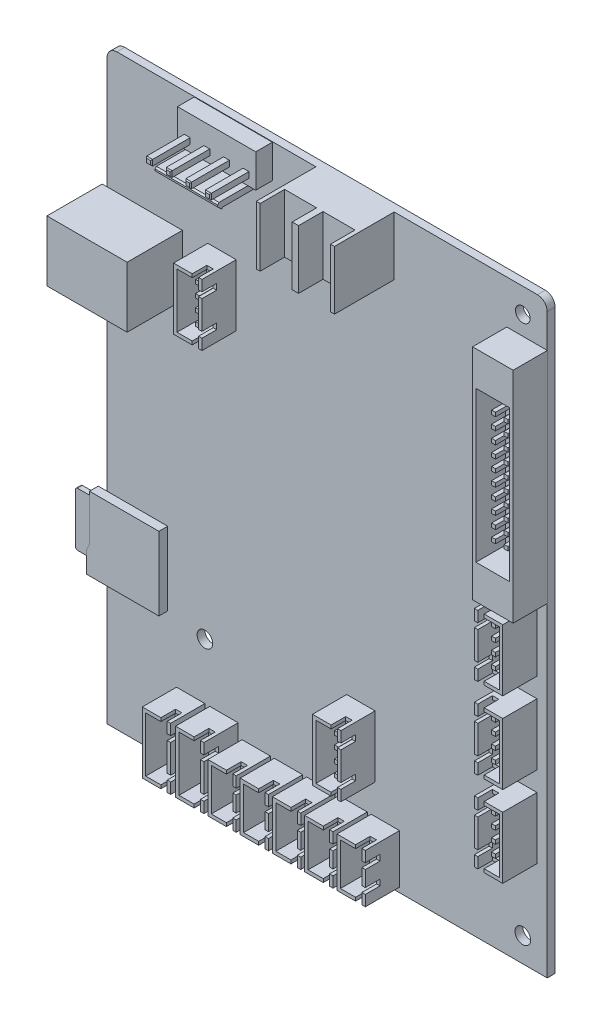
from build123d import *

# Parameters (mm, degrees)
SKETCH_1_R             = 1.5
EXTRUDE_1_DEPTH        = 1.6
SKETCH_2_W             = 16.4
SKETCH_2_H             = 12.4
EXTRUDE_2_DEPTH        = 11.3
SKETCH_3_W             = 3
SKETCH_3_H             = 5.4
CUT_EXTRUDE_1_DEPTH    = 9
EXTRUDE_3_DEPTH        = 1.8
SKETCH_5_W             = 1
SKETCH_5_H             = 11
EXTRUDE_4_DEPTH        = 3
FILLET_1_R             = 0.5
SKETCH_6_W             = 5.8
SKETCH_6_H             = 12.6
EXTRUDE_5_DEPTH        = 7
SKETCH_7_W             = 4.4
SKETCH_7_H             = 11.2
CUT_EXTRUDE_2_DEPTH    = 6
SKETCH_8_W             = 1.3
SKETCH_8_H             = 0.7
SKETCH_8_W_2           = 0.7
SKETCH_8_H_2           = 1.2
CUT_EXTRUDE_3_DEPTH    = 3
PATTERN_LINEAR_1_COUNT = 2
PATTERN_LINEAR_1_PITCH = 6.8
SKETCH_11_W            = 5.8
SKETCH_11_H            = 12.6
EXTRUDE_7_DEPTH        = 7
SKETCH_13_W            = 4.4
SKETCH_13_H            = 11.2
CUT_EXTRUDE_4_DEPTH    = 6
SKETCH_15_W            = 1.3
SKETCH_15_H            = 0.7
SKETCH_15_W_2          = 0.7
SKETCH_15_H_2          = 1.2
CUT_EXTRUDE_5_DEPTH    = 3
SKETCH_17_W            = 0.8
SKETCH_17_H            = 0.8
EXTRUDE_8_DEPTH        = 4.5
EXTRUDE_8_DEPTH_BACK   = 4
SKETCH_19_W            = 5.8
SKETCH_19_H            = 12.6
EXTRUDE_9_DEPTH        = 7
SKETCH_21_W            = 4.4
SKETCH_21_H            = 11.2
CUT_EXTRUDE_6_DEPTH    = 6
SKETCH_23_W            = 1.3
SKETCH_23_H            = 0.7
SKETCH_23_W_2          = 0.7
SKETCH_23_H_2          = 1.2
CUT_EXTRUDE_7_DEPTH    = 3
SKETCH_25_W            = 0.8
SKETCH_25_H            = 0.8
EXTRUDE_10_DEPTH       = 4.5
EXTRUDE_10_DEPTH_BACK  = 4
SKETCH_27_W            = 5.8
SKETCH_27_H            = 12.6
EXTRUDE_11_DEPTH       = 7
SKETCH_29_W            = 4.4
SKETCH_29_H            = 11.2
CUT_EXTRUDE_8_DEPTH    = 6
SKETCH_31_W            = 1.3
SKETCH_31_H            = 0.7
SKETCH_31_W_2          = 0.7
SKETCH_31_H_2          = 1.2
CUT_EXTRUDE_9_DEPTH    = 3
EXTRUDE_START          = -4
SKETCH_33_W            = 0.8
SKETCH_33_H            = 0.8
EXTRUDE_12_DEPTH       = 8.5
PATTERN_LINEAR_2_COUNT = 3
PATTERN_LINEAR_2_PITCH = 16.6
SKETCH_35_W            = 5.8
SKETCH_35_H            = 10
EXTRUDE_13_DEPTH       = 7
SKETCH_37_W            = 4.4
SKETCH_37_H            = 8.6
CUT_EXTRUDE_10_DEPTH   = 6
SKETCH_39_W            = 1.3
SKETCH_39_H            = 0.7
SKETCH_39_W_2          = 0.7
SKETCH_39_H_2          = 1.2
CUT_EXTRUDE_11_DEPTH   = 3
PATTERN_LINEAR_3_COUNT = 5
PATTERN_LINEAR_3_PITCH = 6.6
SKETCH_43_W            = 8.3
SKETCH_43_H            = 44.8
EXTRUDE_15_DEPTH       = 7
SKETCH_45_W            = 6.9
SKETCH_45_H            = 30.8
CUT_EXTRUDE_12_DEPTH   = 6
SKETCH_49_W            = 0.8
SKETCH_49_H            = 0.8
EXTRUDE_16_DEPTH       = 4.5
EXTRUDE_16_DEPTH_BACK  = 4
EXTRUDE_17_DEPTH       = 3.4
EXTRUDE_18_DEPTH       = 12.8
SKETCH_52_W            = 1.2
SKETCH_52_H            = 1.2
EXTRUDE_19_DEPTH       = 7.9
EXTRUDE_19_DEPTH_BACK  = 6
CHAMFER_1_SIZE         = 0.2
SKETCH_53_W            = 16
SKETCH_53_H            = 12
EXTRUDE_20_DEPTH       = 12.2
SKETCH_54_W            = 6.55
SKETCH_54_H            = 12
CUT_EXTRUDE_14_DEPTH   = 5
SKETCH_57_W            = 90
SKETCH_57_H            = 1.6
EXTRUDE_23_DEPTH       = 10
SKETCH_58_R            = 1.6
CUT_EXTRUDE_15_DEPTH   = 10
SKETCH_59_R            = 1.6
CUT_EXTRUDE_16_DEPTH   = 10
SKETCH_60_W            = 2
SKETCH_60_H            = 2
SKETCH_60_W_2          = 2.67575565
SKETCH_60_H_2          = 3.537085726
EXTRUDE_24_DEPTH       = 1.6


with BuildPart() as part:
    # Sketch 1 → Extrude 1 (new body)
    with BuildSketch(Plane.XY):
        with BuildLine():
            Line((43, -55), (-43, -55))
            ThreePointArc((-43, -55), (-44.414213562, -54.414213562), (-45, -53))
            Line((-45, -53), (-45, 53))
            ThreePointArc((-45, 53), (-44.414213562, 54.414213562), (-43, 55))
            Line((-43, 55), (43, 55))
            ThreePointArc((43, 55), (44.414213562, 54.414213562), (45, 53))
            Line((45, 53), (45, -53))
            ThreePointArc((45, -53), (44.414213562, -54.414213562), (43, -55))
        make_face()
        with Locations(Location((40, 50, 0), (0, 0, 180))):
            Circle(SKETCH_1_R, mode=Mode.SUBTRACT)
    extrude(amount=EXTRUDE_1_DEPTH)

    # Sketch 2 → Extrude 2 (add)
    with BuildSketch(Plane.XY.offset(1.6)):
        with Locations((-37.8, 23.9)):
            Rectangle(SKETCH_2_W, SKETCH_2_H)
    extrude(amount=EXTRUDE_2_DEPTH)

    # Sketch 3 → Cut-Extrude 1 (cut)
    with BuildSketch(Plane.ZY.offset(46)):
        Polygon((3, 28.7), (3, 19.1), (9.9, 19.1), (11.5, 20.7), (11.5, 27.1), (9.9, 28.7), align=None)
        with Locations((6.9, 23.9)):
            Rectangle(SKETCH_3_W, SKETCH_3_H, mode=Mode.SUBTRACT)
    extrude(amount=-CUT_EXTRUDE_1_DEPTH, mode=Mode.SUBTRACT)

    # Sketch 4 → Extrude 3 (add)
    with BuildSketch(Plane.XY.offset(1.6)):
        Polygon((-32.6, -23.8), (-32.6, -38.8), (-47.4, -38.8), (-47.4, -34.5), (-46.8, -33.188583942), (-46.8, -23.8), align=None)
    extrude(amount=EXTRUDE_3_DEPTH)

    # Sketch 5 → Extrude 4 (add)
    with BuildSketch(Plane.ZY.offset(46.8)):
        with Locations((2.8, -30.1)):
            Rectangle(SKETCH_5_W, SKETCH_5_H)
    extrude(amount=EXTRUDE_4_DEPTH)

    # Fillet 1
    fillet_1_edges = [part.edges().sort_by_distance(p)[0] for p in [
        (-49.8, -24.6, 2.8),
        (-49.8, -35.6, 2.8),
    ]]
    fillet(fillet_1_edges, radius=FILLET_1_R)

    # Sketch 6 → Extrude 5 (add)
    with BuildSketch(Plane.XY.offset(1.6)):
        with Locations((-27.9, -57.7)):
            Rectangle(SKETCH_6_W, SKETCH_6_H)
    extrude_5 = extrude(amount=EXTRUDE_5_DEPTH)

    # Sketch 7 → Cut-Extrude 2 (cut)
    with BuildSketch(Plane.XY.offset(8.6)):
        with Locations((-27.9, -57.7)):
            Rectangle(SKETCH_7_W, SKETCH_7_H)
    cut_extrude_2 = extrude(amount=-CUT_EXTRUDE_2_DEPTH, mode=Mode.SUBTRACT)

    # Sketch 8 → Cut-Extrude 3 (cut)
    with BuildSketch(Plane.XY.offset(8.6)):
        with Locations((-26.35, -51.75)):
            Rectangle(SKETCH_8_W, SKETCH_8_H)
        with Locations((-25.35, -61.2)):
            Rectangle(SKETCH_8_W_2, SKETCH_8_H_2)
        with Locations((-25.35, -54.2)):
            Rectangle(SKETCH_8_W_2, SKETCH_8_H_2)
        with Locations((-26.35, -63.65)):
            Rectangle(SKETCH_8_W, SKETCH_8_H)
    cut_extrude_3 = extrude(amount=-CUT_EXTRUDE_3_DEPTH, mode=Mode.SUBTRACT)

    # Pattern Linear 1: Extrude 5, Cut-Extrude 2, Cut-Extrude 3 ×2
    with Locations(*[(i * PATTERN_LINEAR_1_PITCH, 0, 0) for i in range(1, PATTERN_LINEAR_1_COUNT)]):
        add(extrude_5)
        add(cut_extrude_2, mode=Mode.SUBTRACT)
        add(cut_extrude_3, mode=Mode.SUBTRACT)

    # Sketch 11 → Extrude 7 (add)
    with BuildSketch(Plane(origin=(33.890716381, 27.460447967, 1.6), x_dir=(1, 0, 0), z_dir=(0, 0, 1))):
        with Locations((-26.990716381, -69.060447967)):
            Rectangle(SKETCH_11_W, SKETCH_11_H)
    extrude(amount=EXTRUDE_7_DEPTH)

    # Sketch 13 → Cut-Extrude 4 (cut)
    with BuildSketch(Plane(origin=(33.890716381, 27.460447967, 8.6), x_dir=(1, 0, 0), z_dir=(0, 0, 1))):
        with Locations((-26.990716381, -69.060447967)):
            Rectangle(SKETCH_13_W, SKETCH_13_H)
    extrude(amount=-CUT_EXTRUDE_4_DEPTH, mode=Mode.SUBTRACT)

    # Sketch 15 → Cut-Extrude 5 (cut)
    with BuildSketch(Plane(origin=(33.890716381, 27.460447967, 8.6), x_dir=(1, 0, 0), z_dir=(0, 0, 1))):
        with Locations((-25.440716381, -63.110447967)):
            Rectangle(SKETCH_15_W, SKETCH_15_H)
        with Locations((-24.440716381, -72.560447967)):
            Rectangle(SKETCH_15_W_2, SKETCH_15_H_2)
        with Locations((-24.440716381, -65.560447967)):
            Rectangle(SKETCH_15_W_2, SKETCH_15_H_2)
        with Locations((-25.440716381, -75.010447967)):
            Rectangle(SKETCH_15_W, SKETCH_15_H)
    extrude(amount=-CUT_EXTRUDE_5_DEPTH, mode=Mode.SUBTRACT)

    # Sketch 17 → Extrude 8 (add, two sides)
    with BuildSketch(Plane(origin=(33.890716381, 27.460447967, 2.6), x_dir=(1, 0, 0), z_dir=(0, 0, 1))) as extrude_8_sk:
        with Locations((-26.490716381, -67.810447967)):
            Rectangle(SKETCH_17_W, SKETCH_17_H)
        with Locations((-26.490716381, -65.310447967)):
            Rectangle(SKETCH_17_W, SKETCH_17_H)
        with Locations((-26.490716381, -70.310447967)):
            Rectangle(SKETCH_17_W, SKETCH_17_H)
        with Locations((-26.490716381, -72.810447967)):
            Rectangle(SKETCH_17_W, SKETCH_17_H)
    extrude(amount=EXTRUDE_8_DEPTH)
    extrude(extrude_8_sk.sketch, amount=-EXTRUDE_8_DEPTH_BACK)

    # Sketch 19 → Extrude 9 (add)
    with BuildSketch(Plane(origin=(2.842311538, 77.877367815, 1.6), x_dir=(1, 0, 0), z_dir=(0, 0, 1))):
        with Locations((-24.342311538, -53.777367815)):
            Rectangle(SKETCH_19_W, SKETCH_19_H)
    extrude(amount=EXTRUDE_9_DEPTH)

    # Sketch 21 → Cut-Extrude 6 (cut)
    with BuildSketch(Plane(origin=(2.842311538, 77.877367815, 8.6), x_dir=(1, 0, 0), z_dir=(0, 0, 1))):
        with Locations((-24.342311538, -53.777367815)):
            Rectangle(SKETCH_21_W, SKETCH_21_H)
    extrude(amount=-CUT_EXTRUDE_6_DEPTH, mode=Mode.SUBTRACT)

    # Sketch 23 → Cut-Extrude 7 (cut)
    with BuildSketch(Plane(origin=(2.842311538, 77.877367815, 8.6), x_dir=(1, 0, 0), z_dir=(0, 0, 1))):
        with Locations((-22.792311538, -47.827367815)):
            Rectangle(SKETCH_23_W, SKETCH_23_H)
        with Locations((-21.792311538, -57.277367815)):
            Rectangle(SKETCH_23_W_2, SKETCH_23_H_2)
        with Locations((-21.792311538, -50.277367815)):
            Rectangle(SKETCH_23_W_2, SKETCH_23_H_2)
        with Locations((-22.792311538, -59.727367815)):
            Rectangle(SKETCH_23_W, SKETCH_23_H)
    extrude(amount=-CUT_EXTRUDE_7_DEPTH, mode=Mode.SUBTRACT)

    # Sketch 25 → Extrude 10 (add, two sides)
    with BuildSketch(Plane(origin=(2.842311538, 77.877367815, 2.6), x_dir=(1, 0, 0), z_dir=(0, 0, 1))) as extrude_10_sk:
        with Locations((-23.842311538, -52.527367815)):
            Rectangle(SKETCH_25_W, SKETCH_25_H)
        with Locations((-23.842311538, -50.027367815)):
            Rectangle(SKETCH_25_W, SKETCH_25_H)
        with Locations((-23.842311538, -55.027367815)):
            Rectangle(SKETCH_25_W, SKETCH_25_H)
        with Locations((-23.842311538, -57.527367815)):
            Rectangle(SKETCH_25_W, SKETCH_25_H)
    extrude(amount=EXTRUDE_10_DEPTH)
    extrude(extrude_10_sk.sketch, amount=-EXTRUDE_10_DEPTH_BACK)

    # Sketch 27 → Extrude 11 (add)
    with BuildSketch(Plane(origin=(67.770164579, 21.085657962, 1.6), x_dir=(1, 0, 0), z_dir=(0, 0, 1))):
        with Locations((-27.770164579, -60.585657962)):
            Rectangle(SKETCH_27_W, SKETCH_27_H)
    extrude_11 = extrude(amount=EXTRUDE_11_DEPTH)

    # Sketch 29 → Cut-Extrude 8 (cut)
    with BuildSketch(Plane(origin=(67.770164579, 21.085657962, 8.6), x_dir=(1, 0, 0), z_dir=(0, 0, 1))):
        with Locations((-27.770164579, -60.585657962)):
            Rectangle(SKETCH_29_W, SKETCH_29_H)
    cut_extrude_8 = extrude(amount=-CUT_EXTRUDE_8_DEPTH, mode=Mode.SUBTRACT)

    # Sketch 31 → Cut-Extrude 9 (cut)
    with BuildSketch(Plane(origin=(67.770164579, 21.085657962, 8.6), x_dir=(1, 0, 0), z_dir=(0, 0, 1))):
        with Locations((-29.320164579, -66.535657962)):
            Rectangle(SKETCH_31_W, SKETCH_31_H)
        with Locations((-30.320164579, -57.085657962)):
            Rectangle(SKETCH_31_W_2, SKETCH_31_H_2)
        with Locations((-30.320164579, -64.085657962)):
            Rectangle(SKETCH_31_W_2, SKETCH_31_H_2)
        with Locations((-29.320164579, -54.635657962)):
            Rectangle(SKETCH_31_W, SKETCH_31_H)
    cut_extrude_9 = extrude(amount=-CUT_EXTRUDE_9_DEPTH, mode=Mode.SUBTRACT)

    # Sketch 33 → Extrude 12 (add)
    with BuildSketch(Plane(origin=(67.770164579, 21.085657962, 2.6), x_dir=(1, 0, 0), z_dir=(0, 0, 1)).offset(EXTRUDE_START)):
        with Locations((-28.270164579, -59.335657962)):
            Rectangle(SKETCH_33_W, SKETCH_33_H)
        with Locations((-28.270164579, -56.835657962)):
            Rectangle(SKETCH_33_W, SKETCH_33_H)
        with Locations((-28.270164579, -61.835657962)):
            Rectangle(SKETCH_33_W, SKETCH_33_H)
        with Locations((-28.270164579, -64.335657962)):
            Rectangle(SKETCH_33_W, SKETCH_33_H)
    extrude_12 = extrude(amount=EXTRUDE_12_DEPTH)

    # Pattern Linear 2: Extrude 11, Cut-Extrude 8, Cut-Extrude 9, Extrude 12 ×3
    with Locations(*[(0, i * PATTERN_LINEAR_2_PITCH, 0) for i in range(1, PATTERN_LINEAR_2_COUNT)]):
        add(extrude_11)
        add(cut_extrude_8, mode=Mode.SUBTRACT)
        add(cut_extrude_9, mode=Mode.SUBTRACT)
        add(extrude_12)

    # Sketch 35 → Extrude 13 (add)
    with BuildSketch(Plane(origin=(13.449868443, -1.02285018, 1.6), x_dir=(1, 0, 0), z_dir=(0, 0, 1))):
        with Locations((-27.949868443, -57.97714982)):
            Rectangle(SKETCH_35_W, SKETCH_35_H)
    extrude_13 = extrude(amount=EXTRUDE_13_DEPTH)

    # Sketch 37 → Cut-Extrude 10 (cut)
    with BuildSketch(Plane(origin=(13.449868443, -1.02285018, 8.6), x_dir=(1, 0, 0), z_dir=(0, 0, 1))):
        with Locations((-27.949868443, -57.97714982)):
            Rectangle(SKETCH_37_W, SKETCH_37_H)
    cut_extrude_10 = extrude(amount=-CUT_EXTRUDE_10_DEPTH, mode=Mode.SUBTRACT)

    # Sketch 39 → Cut-Extrude 11 (cut)
    with BuildSketch(Plane(origin=(13.449868443, -1.02285018, 8.6), x_dir=(1, 0, 0), z_dir=(0, 0, 1))):
        with Locations((-26.399868443, -53.32714982)):
            Rectangle(SKETCH_39_W, SKETCH_39_H)
        with Locations((-25.399868443, -60.17714982)):
            Rectangle(SKETCH_39_W_2, SKETCH_39_H_2)
        with Locations((-25.399868443, -55.77714982)):
            Rectangle(SKETCH_39_W_2, SKETCH_39_H_2)
        with Locations((-26.399868443, -62.62714982)):
            Rectangle(SKETCH_39_W, SKETCH_39_H)
    cut_extrude_11 = extrude(amount=-CUT_EXTRUDE_11_DEPTH, mode=Mode.SUBTRACT)

    # Pattern Linear 3: Extrude 13, Cut-Extrude 10, Cut-Extrude 11 ×5
    with Locations(*[(i * PATTERN_LINEAR_3_PITCH, 0, 0) for i in range(1, PATTERN_LINEAR_3_COUNT)]):
        add(extrude_13)
        add(cut_extrude_10, mode=Mode.SUBTRACT)
        add(cut_extrude_11, mode=Mode.SUBTRACT)

    # Sketch 43 → Extrude 15 (add)
    with BuildSketch(Plane(origin=(66.890855613, 85.562649537, 1.6), x_dir=(1, 0, 0), z_dir=(0, 0, 1))):
        with Locations((-26.016484293, -61.827338231)):
            Rectangle(SKETCH_43_W, SKETCH_43_H)
    extrude(amount=EXTRUDE_15_DEPTH)

    # Sketch 45 → Cut-Extrude 12 (cut)
    with BuildSketch(Plane(origin=(66.890855613, 85.562649537, 8.6), x_dir=(1, 0, 0), z_dir=(0, 0, 1))):
        with Locations((-26.016484293, -61.827338231)):
            Rectangle(SKETCH_45_W, SKETCH_45_H)
    extrude(amount=-CUT_EXTRUDE_12_DEPTH, mode=Mode.SUBTRACT)

    # Sketch 49 → Extrude 16 (add, two sides)
    with BuildSketch(Plane(origin=(66.890855613, 85.562649537, 2.6), x_dir=(1, 0, 0), z_dir=(0, 0, 1))) as extrude_16_sk:
        with Locations((-27.366484293, -53.077338231)):
            Rectangle(SKETCH_49_W, SKETCH_49_H)
        with Locations((-27.366484293, -50.577338231)):
            Rectangle(SKETCH_49_W, SKETCH_49_H)
        with Locations((-27.366484293, -55.577338231)):
            Rectangle(SKETCH_49_W, SKETCH_49_H)
        with Locations((-27.366484293, -58.077338231)):
            Rectangle(SKETCH_49_W, SKETCH_49_H)
        with Locations((-27.366484293, -60.577338231)):
            Rectangle(SKETCH_49_W, SKETCH_49_H)
        with Locations((-27.366484293, -63.077338231)):
            Rectangle(SKETCH_49_W, SKETCH_49_H)
        with Locations((-27.366484293, -65.577338231)):
            Rectangle(SKETCH_49_W, SKETCH_49_H)
        with Locations((-27.366484293, -68.077338231)):
            Rectangle(SKETCH_49_W, SKETCH_49_H)
        with Locations((-27.366484293, -70.577338231)):
            Rectangle(SKETCH_49_W, SKETCH_49_H)
        with Locations((-27.366484293, -73.077338231)):
            Rectangle(SKETCH_49_W, SKETCH_49_H)
        with Locations((-24.806484293, -53.077338231)):
            Rectangle(SKETCH_49_W, SKETCH_49_H)
        with Locations((-24.806484293, -50.577338231)):
            Rectangle(SKETCH_49_W, SKETCH_49_H)
        with Locations((-24.806484293, -55.577338231)):
            Rectangle(SKETCH_49_W, SKETCH_49_H)
        with Locations((-24.806484293, -58.077338231)):
            Rectangle(SKETCH_49_W, SKETCH_49_H)
        with Locations((-24.806484293, -60.577338231)):
            Rectangle(SKETCH_49_W, SKETCH_49_H)
        with Locations((-24.806484293, -63.077338231)):
            Rectangle(SKETCH_49_W, SKETCH_49_H)
        with Locations((-24.806484293, -65.577338231)):
            Rectangle(SKETCH_49_W, SKETCH_49_H)
        with Locations((-24.806484293, -68.077338231)):
            Rectangle(SKETCH_49_W, SKETCH_49_H)
        with Locations((-24.806484293, -70.577338231)):
            Rectangle(SKETCH_49_W, SKETCH_49_H)
        with Locations((-24.806484293, -73.077338231)):
            Rectangle(SKETCH_49_W, SKETCH_49_H)
    extrude(amount=EXTRUDE_16_DEPTH)
    extrude(extrude_16_sk.sketch, amount=-EXTRUDE_16_DEPTH_BACK)

    # Sketch 50 → Extrude 17 (add)
    with BuildSketch(Plane.XY.offset(1.6)):
        Polygon((-27.2, 48.1), (-25.6, 48.1), (-25.6, 46.9), (-12.8, 46.9), (-12.8, 48.1), (-11.2, 48.1), (-11.2, 54.9), (-27.2, 54.9), align=None)
    extrude(amount=EXTRUDE_17_DEPTH)

    # Sketch 51 → Extrude 18 (add)
    with BuildSketch(Plane.ZY.offset(25.6)):
        Polygon((5, 48.1), (10.91957102, 48.1), (11.2, 47.77565278), (11.2, 47.432802572), (10.306017135, 46.588258916), (10.306017135, 46.9), (5, 46.9), align=None)
    extrude(amount=-EXTRUDE_18_DEPTH)

    # Sketch 52 → Extrude 19 (add, two sides)
    with BuildSketch(Plane.XY.offset(5)) as extrude_19_sk:
        with Locations((-17.2, 50.1)):
            Rectangle(SKETCH_52_W, SKETCH_52_H)
        with Locations((-13.2, 50.1)):
            Rectangle(SKETCH_52_W, SKETCH_52_H)
        with Locations((-21.2, 50.1)):
            Rectangle(SKETCH_52_W, SKETCH_52_H)
        with Locations((-25.2, 50.1)):
            Rectangle(SKETCH_52_W, SKETCH_52_H)
    extrude(amount=EXTRUDE_19_DEPTH)
    extrude(extrude_19_sk.sketch, amount=-EXTRUDE_19_DEPTH_BACK)

    # Chamfer 1
    chamfer_1_edges = [part.edges().sort_by_distance(p)[0] for p in [
        (-13.8, 50.1, 12.9),
        (-13.2, 49.5, 12.9),
        (-12.6, 50.1, 12.9),
        (-13.2, 50.7, 12.9),
        (-17.8, 50.1, 12.9),
        (-17.2, 49.5, 12.9),
        (-16.6, 50.1, 12.9),
        (-17.2, 50.7, 12.9),
        (-21.8, 50.1, 12.9),
        (-21.2, 49.5, 12.9),
        (-20.6, 50.1, 12.9),
        (-21.2, 50.7, 12.9),
        (-25.8, 50.1, 12.9),
        (-25.2, 49.5, 12.9),
        (-24.6, 50.1, 12.9),
        (-25.2, 50.7, 12.9),
    ]]
    chamfer(chamfer_1_edges, length=CHAMFER_1_SIZE)

    # Sketch 53 → Extrude 20 (add)
    with BuildSketch(Plane.XY.offset(1.6)):
        with Locations((5.7, 49)):
            Rectangle(SKETCH_53_W, SKETCH_53_H)
    extrude(amount=EXTRUDE_20_DEPTH)

    # Sketch 54 → Cut-Extrude 14 (cut)
    with BuildSketch(Plane.XY.offset(13.8)):
        with Locations((1.775, 49)):
            Rectangle(SKETCH_54_W, SKETCH_54_H)
        with Locations((9.625, 49)):
            Rectangle(SKETCH_54_W, SKETCH_54_H)
    extrude(amount=-CUT_EXTRUDE_14_DEPTH, mode=Mode.SUBTRACT)

    # Sketch 57 → Extrude 23 (add)
    with BuildSketch(Plane.XZ.offset(55)):
        with Locations((0, 0.8)):
            Rectangle(SKETCH_57_W, SKETCH_57_H)
    extrude(amount=EXTRUDE_23_DEPTH)

    # Sketch 58 → Cut-Extrude 15 (cut)
    with BuildSketch(Plane.XY.offset(1.6)):
        with Locations((40, -60)):
            Circle(SKETCH_58_R)
    extrude(amount=-CUT_EXTRUDE_15_DEPTH, mode=Mode.SUBTRACT)

    # Sketch 59 → Cut-Extrude 16 (cut)
    with BuildSketch(Plane.XY.offset(1.6)):
        with Locations((-25, -40)):
            Circle(SKETCH_59_R)
        with Locations((-25, 40)):
            Circle(SKETCH_59_R)
    extrude(amount=-CUT_EXTRUDE_16_DEPTH, mode=Mode.SUBTRACT)

    # Sketch 60 → Extrude 24 (add)
    with BuildSketch(Plane.XY.offset(1.6)):
        with Locations((-44, -54)):
            Rectangle(SKETCH_60_W, SKETCH_60_H)
        with Locations((43.662122175, -53.231457137)):
            Rectangle(SKETCH_60_W_2, SKETCH_60_H_2)
    extrude(amount=-EXTRUDE_24_DEPTH)


solid = part.part
